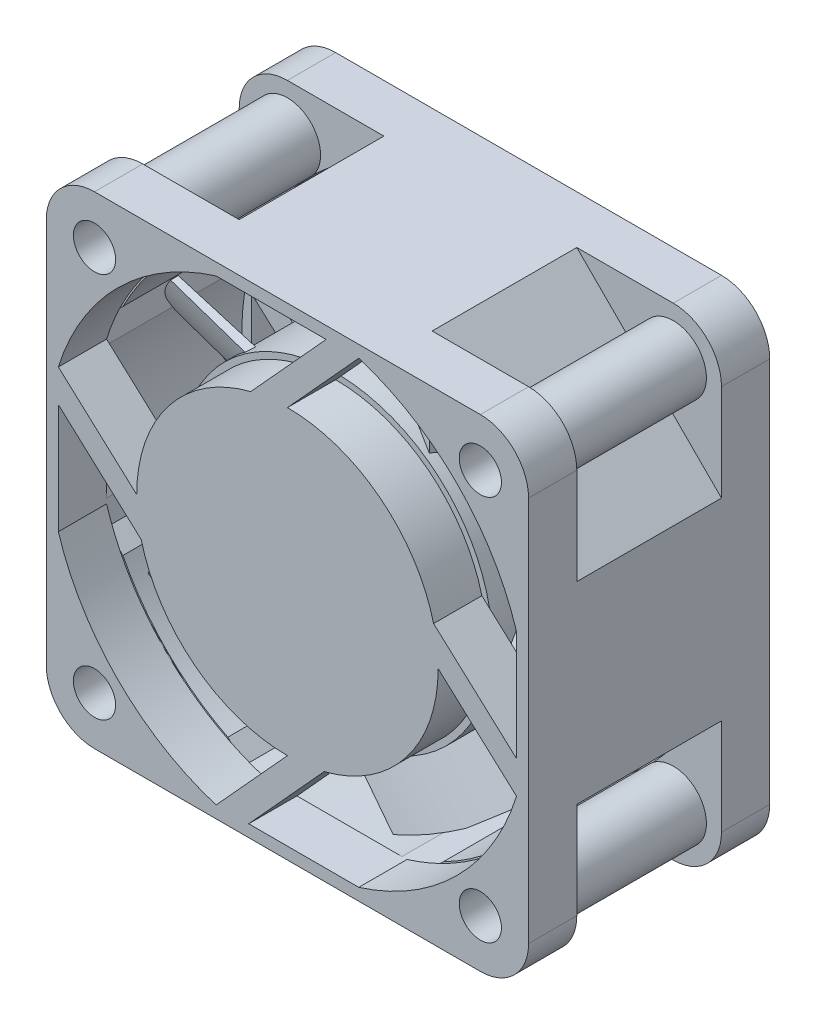
from build123d import *

# Parameters (mm, degrees)
SKETCH1_R           = 1.75
SKETCH1_R_2         = 12.5
BOSS_EXTRUDE1_DEPTH = 4
BOSS_EXTRUDE2_DEPTH = 12
SKETCH3_R           = 13
BOSS_EXTRUDE3_DEPTH = 12
CIRPATTERN8_COUNT   = 5
SKETCH9_R           = 19.78
SKETCH9_R_2         = 18.78
CUT_EXTRUDE1_DEPTH  = 12
SKETCH10_R          = 2.75
SKETCH10_R_2        = 1.75
BOSS_EXTRUDE4_DEPTH = 12


with BuildPart() as part:
    # Sketch1 → Boss-Extrude1 (new body)
    with BuildSketch(Plane.XY):
        with BuildLine():
            Line((-16, -20), (16, -20))
            ThreePointArc((16, -20), (18.828427125, -18.828427125), (20, -16))
            Line((20, -16), (20, 16))
            ThreePointArc((20, 16), (18.828427125, 18.828427125), (16, 20))
            Line((16, 20), (-16, 20))
            ThreePointArc((-16, 20), (-18.828427125, 18.828427125), (-20, 16))
            Line((-20, 16), (-20, -16))
            ThreePointArc((-20, -16), (-18.828427125, -18.828427125), (-16, -20))
        make_face()
        with Locations((-16, -16)):
            Circle(SKETCH1_R, mode=Mode.SUBTRACT)
        with Locations((-16, 16)):
            Circle(SKETCH1_R, mode=Mode.SUBTRACT)
        with Locations((16, -16)):
            Circle(SKETCH1_R, mode=Mode.SUBTRACT)
        with Locations((16, 16)):
            Circle(SKETCH1_R, mode=Mode.SUBTRACT)
        with BuildLine():
            ThreePointArc((-19, -5.916924877), (-14.071424946, -14.071424946), (-5.916924877, -19))
            Line((-5.916924877, -19), (5.916924877, -19))
            ThreePointArc((5.916924877, -19), (14.071424946, -14.071424946), (19, -5.916924877))
            Line((19, -5.916924877), (19, 5.916924877))
            ThreePointArc((19, 5.916924877), (14.071424946, 14.071424946), (5.916924877, 19))
            Line((5.916924877, 19), (-5.916924877, 19))
            ThreePointArc((-5.916924877, 19), (-14.071424946, 14.071424946), (-19, 5.916924877))
            Line((-19, 5.916924877), (-19, -5.916924877))
        make_face(mode=Mode.SUBTRACT)
        Circle(SKETCH1_R_2)
        with BuildLine():
            Line((3.212381253, 19), (-3.048005623, 12.122692016))
            ThreePointArc((-3.048005623, 12.122692016), (-1.535635015, 12.405314389), (0, 12.5))
            Line((0, 12.5), (5.916924877, 19))
            Line((5.916924877, 19), (3.212381253, 19))
        make_face()
        with BuildLine():
            Line((19, -3.212381253), (12.122692016, 3.048005623))
            ThreePointArc((12.122692016, 3.048005623), (12.405314389, 1.535635015), (12.5, 0))
            Line((12.5, 0), (19, -5.916924877))
            Line((19, -5.916924877), (19, -3.212381253))
        make_face()
        with BuildLine():
            Line((0, -12.5), (-5.916924877, -19))
            Line((-5.916924877, -19), (-3.212381253, -19))
            Line((-3.212381253, -19), (3.048005623, -12.122692016))
            ThreePointArc((3.048005623, -12.122692016), (1.535635015, -12.405314389), (0, -12.5))
        make_face()
        with BuildLine():
            Line((-12.5, 0), (-19, 5.916924877))
            Line((-19, 5.916924877), (-19, 3.212381253))
            Line((-19, 3.212381253), (-12.122692016, -3.048005623))
            ThreePointArc((-12.122692016, -3.048005623), (-12.405314389, -1.535635015), (-12.5, 0))
        make_face()
    boss_extrude1 = extrude(amount=BOSS_EXTRUDE1_DEPTH)

    # Sketch2 → Boss-Extrude2 (add)
    with BuildSketch(Plane.XY.offset(4)):
        Polygon((-8, 20), (8, 20), (20, 8), (20, -8), (8, -20), (-8, -20), (-20, -8), (-20, 8), align=None)
        Polygon((-19, 7.585786438), (-7.585786438, 19), (7.585786438, 19), (19, 7.585786438), (19, -7.585786438), (7.585786438, -19), (-7.585786438, -19), (-19, -7.585786438), align=None, mode=Mode.SUBTRACT)
    extrude(amount=BOSS_EXTRUDE2_DEPTH)

    # Sketch3 → Boss-Extrude3 (add)
    with BuildSketch(Plane.XY.offset(4)):
        with Locations(Location((0, 0, 0), (0, 0, 178.024599217))):
            Circle(SKETCH3_R)
    extrude(amount=BOSS_EXTRUDE3_DEPTH)

    # Sketch6 → Loft1 section 0
    with BuildSketch(Plane(origin=(0, 10.5, 0), x_dir=(1, 0, 0), z_dir=(0, 1, 0))):
        with BuildLine():
            Line((-7.634653594, -4.868194635), (-7.916570624, -5.508915158))
            add(Edge.make_bspline(
                [(7.358820688, -15.598731577), (6.949311009, -15.452704869), (6.129654961, -15.134792576), (4.605406603, -14.411527383), (2.842854067, -13.366507696), (0.917414721, -11.965179802), (-1.477618084, -10.005392672), (-4.292715948, -7.566197041), (-6.633321712, -6.073544679), (-7.916570624, -5.508915158)],
                knots=[-0.004802341, -0.004802341, -0.004802341, -0.004802341, 0.058374067, 0.121550476, 0.247903292, 0.374256108, 0.500608924, 0.753314557, 1.00602019, 1.00602019, 1.00602019, 1.00602019], degree=3))
            Line((7.358820688, -15.598731577), (7.593932356, -14.939396682))
            add(Edge.make_bspline(
                [(-7.634653594, -4.868194635), (-6.301252312, -5.454891199), (-3.84087918, -7.025724217), (-1.017423849, -9.478486731), (1.351908373, -11.415790957), (3.234775492, -12.785214387), (4.941506428, -13.796388429), (6.412531915, -14.493805972), (7.200091263, -14.798957222), (7.593932356, -14.939396682)],
                knots=[-0.005013509, -0.005013509, -0.005013509, -0.005013509, 0.247692662, 0.500398834, 0.62675192, 0.753105006, 0.879458092, 0.942634635, 1.005811177, 1.005811177, 1.005811177, 1.005811177], degree=3))
        make_face()
    # Sketch5 → Loft1 section 1
    with BuildSketch(Plane(origin=(0, 18.5, 0), x_dir=(1, 0, 0), z_dir=(0, 1, 0))):
        with BuildLine():
            Line((-7.583395952, -5), (-7.784765259, -5.457657516))
            add(Edge.make_bspline(
                [(7.29821737, -15.470953496), (0.760384835, -13.139633368), (-2.71673531, -7.687590694), (-7.784765259, -5.457657516)],
                knots=[0, 0, 0, 0, 1, 1, 1, 1], degree=3))
            Line((7.29821737, -15.470953496), (7.466154276, -15))
            add(Edge.make_bspline(
                [(7.466154276, -15), (7.074750539, -14.860429675), (6.294276097, -14.550123211), (4.837129738, -13.853440893), (3.14391002, -12.843839409), (1.276869099, -11.483722199), (-1.070434925, -9.563346416), (-3.866055888, -7.143676825), (-6.270817684, -5.577534438), (-7.583395952, -5)],
                knots=[0, 0, 0, 0, 0.0625, 0.125, 0.25, 0.375, 0.5, 0.75, 1, 1, 1, 1], degree=3))
        make_face()
    loft1 = loft()

    # CirPattern8: Loft1 ×5 about axis
    cirpattern8_axis = Axis((0, 0, 16), (0, 0, 1))
    for i in range(1, CIRPATTERN8_COUNT):
        add(loft1.rotate(cirpattern8_axis, i * 360 / CIRPATTERN8_COUNT))

    # Mirror1: Boss-Extrude1 across plane
    add(boss_extrude1.mirror(Plane(origin=(0, 0, 10), x_dir=(1, 0, 0), z_dir=(0, 0, -1))))

    # Sketch9 → Cut-Extrude1 (cut)
    with BuildSketch(Plane(origin=(0, 0, 16), x_dir=(-1, 0, 0), z_dir=(0, 0, -1))):
        Circle(SKETCH9_R)
        Circle(SKETCH9_R_2, mode=Mode.SUBTRACT)
    extrude(amount=CUT_EXTRUDE1_DEPTH, mode=Mode.SUBTRACT)


with BuildPart() as cut_extrude1_kept_piece:
    # of the separate pieces the step leaves, the one the design keeps (cut_extrude1_pieces_kept)
    add(part.part.solids().sort_by_distance((-16, -20, 0))[0])

    # Sketch10 → Boss-Extrude4 (add)
    with BuildSketch(Plane(origin=(0, 0, 16), x_dir=(-1, 0, 0), z_dir=(0, 0, -1))):
        with Locations(Location((-16, 16, 0), (0, 0, 308.111740531))):
            Circle(SKETCH10_R)
        with Locations(Location((-16, 16, 0), (0, 0, 180))):
            Circle(SKETCH10_R_2, mode=Mode.SUBTRACT)
        with Locations(Location((16, 16, 0), (0, 0, 218.111740531))):
            Circle(SKETCH10_R)
        with Locations(Location((16, 16, 0), (0, 0, 180))):
            Circle(SKETCH10_R_2, mode=Mode.SUBTRACT)
        with Locations(Location((16, -16, 0), (0, 0, 141.888259469))):
            Circle(SKETCH10_R)
        with Locations(Location((16, -16, 0), (0, 0, 180))):
            Circle(SKETCH10_R_2, mode=Mode.SUBTRACT)
        with Locations(Location((-16, -16, 0), (0, 0, 51.888259469))):
            Circle(SKETCH10_R)
        with Locations(Location((-16, -16, 0), (0, 0, 180))):
            Circle(SKETCH10_R_2, mode=Mode.SUBTRACT)
    extrude(amount=BOSS_EXTRUDE4_DEPTH)


solid = cut_extrude1_kept_piece.part
